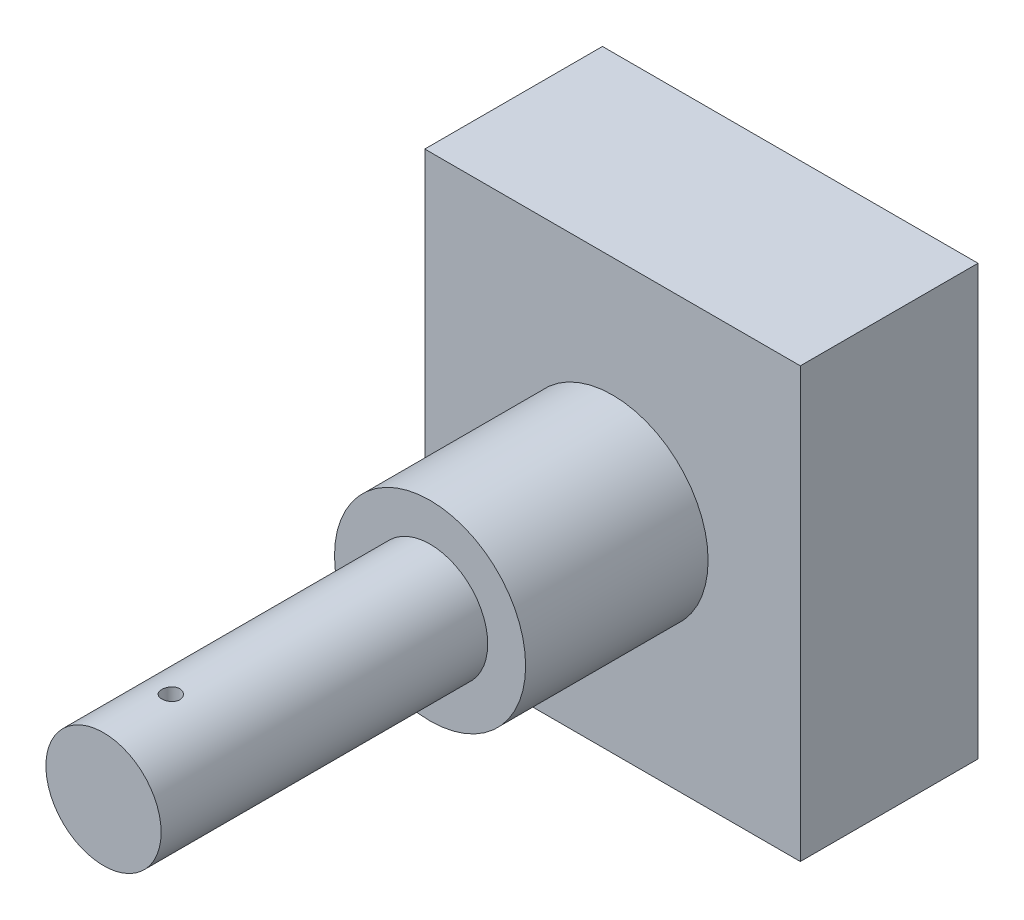
from build123d import *

# Parameters (mm, degrees)
SKETCH1_R                      = 4.975
BOSS_EXTRUDE1_DEPTH            = 9.5
SKETCH2_R                      = 3
BOSS_EXTRUDE2_DEPTH            = 17
CUT_EXTRUDE1_REACH             = 6.975
SKETCH3_R                      = 0.465864979
CUT_EXTRUDE1_DIRECTION_2_REACH = 6.975
SKETCH5_W                      = 19.55
SKETCH5_H                      = 22.35
BOSS_EXTRUDE4_DEPTH            = 9.25


with BuildPart() as part:
    # Sketch1 → Boss-Extrude1 (new body)
    with BuildSketch(Plane.XY):
        Circle(SKETCH1_R)
    extrude(amount=BOSS_EXTRUDE1_DEPTH)

    # Sketch2 → Boss-Extrude2 (add)
    with BuildSketch(Plane.XY.offset(9.5)):
        Circle(SKETCH2_R)
    extrude(amount=BOSS_EXTRUDE2_DEPTH)

    # Sketch3 → Cut-Extrude1 (cut, up to next)
    with BuildSketch(Plane(origin=(0, 0, 0), x_dir=(1, 0, 0), z_dir=(0, 1, 0)), mode=Mode.PRIVATE) as cut_extrude1_sk1:
        with Locations((0, -23)):
            Circle(SKETCH3_R)
    cut_extrude1_tool1 = extrude(cut_extrude1_sk1.sketch, amount=-CUT_EXTRUDE1_REACH, mode=Mode.PRIVATE) & part.part
    add(cut_extrude1_tool1.solids().sort_by_distance((0, 0, 23))[0], mode=Mode.SUBTRACT)

    # Sketch3 → Cut-Extrude1 direction 2 (cut, up to next)
    with BuildSketch(Plane(origin=(0, 0, 0), x_dir=(1, 0, 0), z_dir=(0, 1, 0)), mode=Mode.PRIVATE) as cut_extrude1_direction_2_sk1:
        with Locations((0, -23)):
            Circle(SKETCH3_R)
    cut_extrude1_direction_2_tool1 = extrude(cut_extrude1_direction_2_sk1.sketch, amount=CUT_EXTRUDE1_DIRECTION_2_REACH, mode=Mode.PRIVATE) & part.part
    add(cut_extrude1_direction_2_tool1.solids().sort_by_distance((0, 0, 23))[0], mode=Mode.SUBTRACT)

    # Sketch5 → Boss-Extrude4 (add)
    with BuildSketch(Plane(origin=(0, 0, 0), x_dir=(-1, 0, 0), z_dir=(0, 0, -1))):
        Rectangle(SKETCH5_W, SKETCH5_H)
    extrude(amount=BOSS_EXTRUDE4_DEPTH)


solid = part.part
